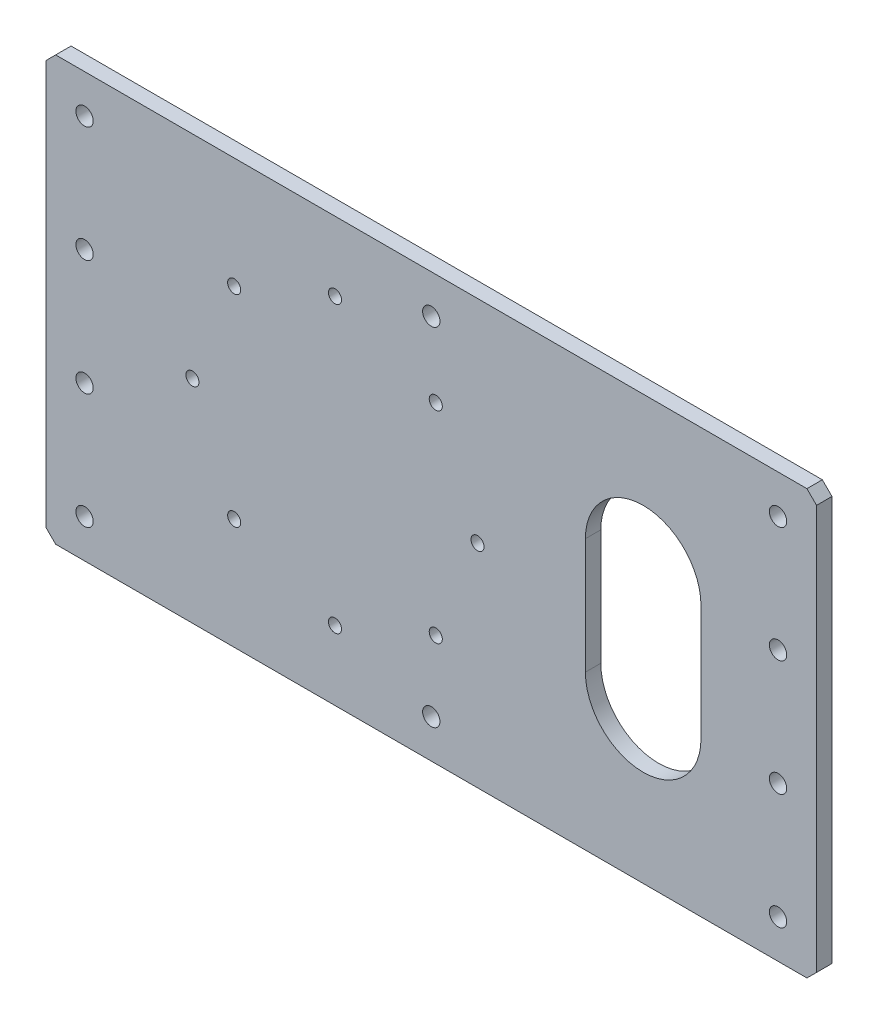
from build123d import *

# Parameters (mm, degrees)
SKETCH_1_W             = 400
SKETCH_1_H             = 220
EXTRUDE_1_DEPTH        = 8
SKETCH_3_R             = 2.5
SKETCH_3_R_2           = 2.325901808
CUT_EXTRUDE_1_DEPTH    = 10
SKETCH_4_R             = 4.5
CUT_EXTRUDE_2_DEPTH    = 10
CUT_EXTRUDE_3_DEPTH    = 10
HOLE_WIZARD_M8_1_D     = 6.8
HOLE_WIZARD_M8_1_DEPTH = 8
HOLE_WIZARD_M8_2_D     = 6.8
HOLE_WIZARD_M8_2_DEPTH = 8
HOLE_WIZARD_M8_3_D     = 6.8
HOLE_WIZARD_M8_3_DEPTH = 8
CHAMFER_1_SIZE         = 5
SKETCH_12_R            = 4.5
CUT_EXTRUDE_4_DEPTH    = 10


with BuildPart() as part:
    # 草图1 → 凸台-拉伸1 (new body)
    with BuildSketch(Plane.XY):
        Rectangle(SKETCH_1_W, SKETCH_1_H)
    extrude(amount=EXTRUDE_1_DEPTH)

    # 草图3 → 切除-拉伸1 (cut)
    with BuildSketch(Plane.XY.offset(8)):
        with Locations((24, 0)):
            Circle(SKETCH_3_R)
        with Locations((-50, -74)):
            Circle(SKETCH_3_R)
        with Locations((-124, 0)):
            Circle(SKETCH_3_R)
        with Locations((-50, 74)):
            Circle(SKETCH_3_R)
        with Locations((2.325901808, 52.325901808)):
            Circle(SKETCH_3_R_2)
        with Locations((2.325901808, -52.325901808)):
            Circle(SKETCH_3_R_2)
        with Locations((-102.325901808, -52.325901808)):
            Circle(SKETCH_3_R_2)
        with Locations((-102.325901808, 52.325901808)):
            Circle(SKETCH_3_R_2)
    extrude(amount=-CUT_EXTRUDE_1_DEPTH, mode=Mode.SUBTRACT)

    # 草图4 → 切除-拉伸2 (cut)
    with BuildSketch(Plane(origin=(0, 0, 0), x_dir=(-1, 0, 0), z_dir=(0, 0, -1))):
        with Locations((180, 30)):
            Circle(SKETCH_4_R)
        with Locations((180, 90)):
            Circle(SKETCH_4_R)
        with Locations((180, -30)):
            Circle(SKETCH_4_R)
        with Locations((180, -90)):
            Circle(SKETCH_4_R)
        with Locations((-180, -90)):
            Circle(SKETCH_4_R)
        with Locations((-180, -30)):
            Circle(SKETCH_4_R)
        with Locations((-180, 90)):
            Circle(SKETCH_4_R)
        with Locations((-180, 30)):
            Circle(SKETCH_4_R)
    extrude(amount=-CUT_EXTRUDE_2_DEPTH, mode=Mode.SUBTRACT)

    # 草图5 → 切除-拉伸3 (cut)
    with BuildSketch(Plane(origin=(0, 0, 0), x_dir=(-1, 0, 0), z_dir=(0, 0, -1))):
        with BuildLine():
            Line((-80, 30), (-80, -30))
            ThreePointArc((-80, -30), (-110, -60), (-140, -30))
            Line((-140, -30), (-140, 30))
            ThreePointArc((-140, 30), (-110, 60), (-80, 30))
        make_face()
    extrude(amount=-CUT_EXTRUDE_3_DEPTH, mode=Mode.SUBTRACT)

    # M8 螺纹孔1
    with Locations(Plane(origin=(0, 0, 0), x_dir=(-1, 0, 0), z_dir=(0, 0, -1))):
        with Locations((50, 74), (124, 0), (50, -74), (-24, 0)):
            Hole(HOLE_WIZARD_M8_1_D / 2, depth=HOLE_WIZARD_M8_1_DEPTH)

    # M8 螺纹孔2
    with Locations(Plane(origin=(0, 0, 0), x_dir=(-1, 0, 0), z_dir=(0, 0, -1))):
        with Locations((-2.325901808, 52.325901808)):
            Hole(HOLE_WIZARD_M8_2_D / 2, depth=HOLE_WIZARD_M8_2_DEPTH)

    # M8 螺纹孔3
    with Locations(Plane(origin=(0, 0, 0), x_dir=(-1, 0, 0), z_dir=(0, 0, -1))):
        with Locations((102.325901808, 52.325901808), (102.325901808, -52.325901808), (-2.325901808, -52.325901808)):
            Hole(HOLE_WIZARD_M8_3_D / 2, depth=HOLE_WIZARD_M8_3_DEPTH)

    # 倒角1
    chamfer_1_edges = [part.edges().sort_by_distance(p)[0] for p in [
        (-200, 110, 4),
        (200, 110, 4),
        (200, -110, 4),
        (-200, -110, 4),
    ]]
    chamfer(chamfer_1_edges, length=CHAMFER_1_SIZE)

    # 草图12 → 切除-拉伸4 (cut)
    with BuildSketch(Plane(origin=(0, 0, 0), x_dir=(-1, 0, 0), z_dir=(0, 0, -1))):
        with Locations((0, 90)):
            Circle(SKETCH_12_R)
        with Locations((0, -90)):
            Circle(SKETCH_12_R)
    extrude(amount=-CUT_EXTRUDE_4_DEPTH, mode=Mode.SUBTRACT)


solid = part.part
